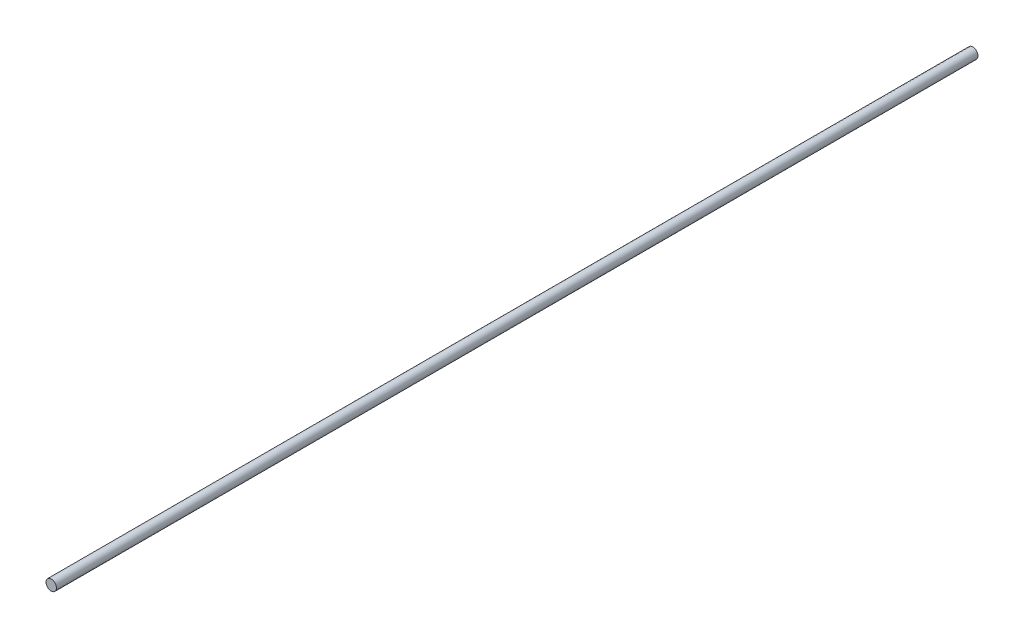
from build123d import *

# Parameters (mm, degrees)
SKETCH1_R           = 3.96875
BOSS_EXTRUDE1_DEPTH = 700


with BuildPart() as part:
    # Sketch1 → Boss-Extrude1 (new body)
    with BuildSketch(Plane.XY):
        Circle(SKETCH1_R)
    extrude(amount=-BOSS_EXTRUDE1_DEPTH)


solid = part.part
